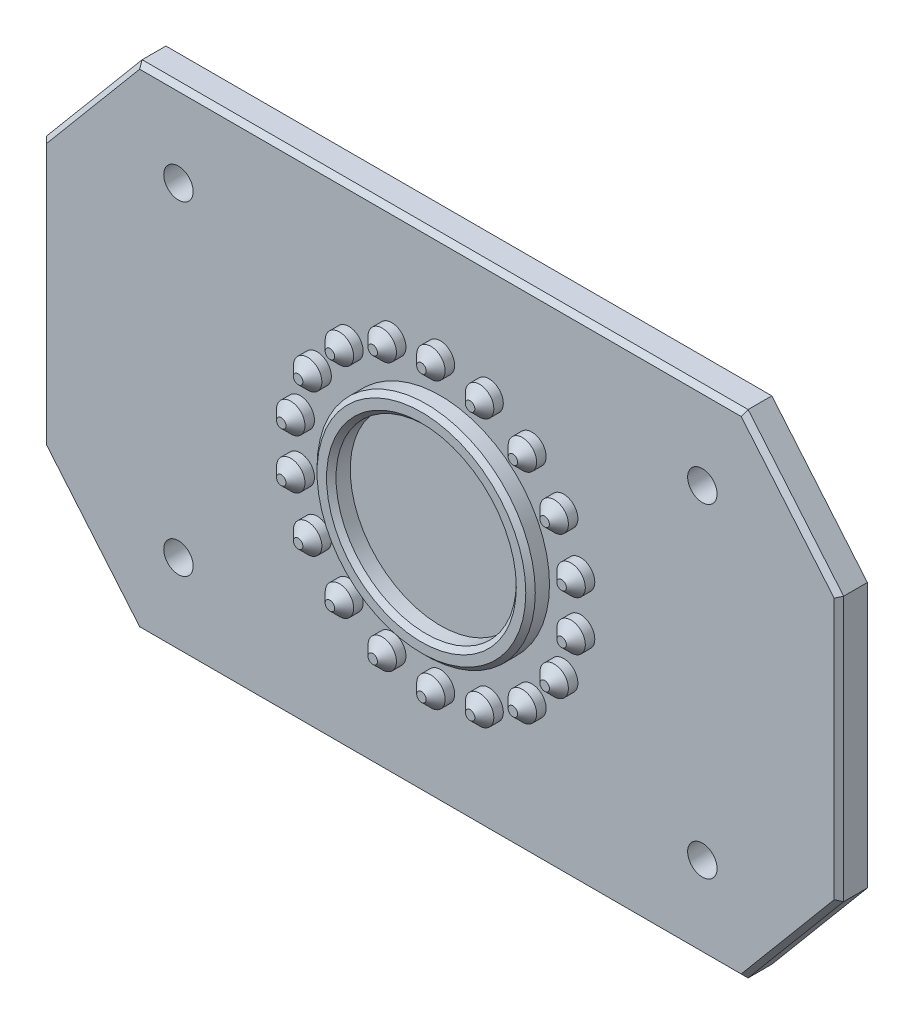
from build123d import *

# Parameters (mm, degrees)
SKETCH1_R           = 9.5
BOSS_EXTRUDE1_DEPTH = 3
CHAMFER1_SIZE       = 0.5
CUT_EXTRUDE1_REACH  = 124.813
SKETCH2_R           = 1.55
SKETCH3_R           = 1.5
BOSS_EXTRUDE2_DEPTH = 2
CHAMFER2_SIZE       = 1
SKETCH4_R           = 11.5
SKETCH4_R_2         = 9.5
BOSS_EXTRUDE3_DEPTH = 2
CHAMFER3_SIZE       = 0.5


with BuildPart() as part:
    # Sketch1 → Boss-Extrude1 (new body)
    with BuildSketch(Plane.XY):
        Polygon((-110, 14.650482688), (-99.930804426, 2.650482688), (-36.069195574, 2.650482688), (-26, 14.650482688), (-26, 42.534332436), (-36.069195574, 54.534332436), (-99.930804426, 54.534332436), (-110, 42.534332436), align=None)
        with Locations((-68, 28.592407562)):
            Circle(SKETCH1_R, mode=Mode.SUBTRACT)
        with Locations((-68, 28.592407562)):
            Circle(SKETCH1_R)
    extrude(amount=BOSS_EXTRUDE1_DEPTH)

    # Chamfer1
    chamfer1_edges = [part.edges().sort_by_distance(p)[0] for p in [
        (-31.034597787, 8.650482688, 3),
        (-26, 28.592407562, 3),
        (-31.034597787, 48.534332436, 3),
        (-68, 54.534332436, 3),
        (-104.965402213, 48.534332436, 3),
        (-110, 28.592407562, 3),
        (-104.965402213, 8.650482688, 3),
        (-68, 2.650482688, 3),
    ]]
    chamfer(chamfer1_edges, length=CHAMFER1_SIZE)

    # Sketch2 → Cut-Extrude1 (cut, up to next)
    with BuildSketch(Plane(origin=(0, 0, 0), x_dir=(-1, 0, 0), z_dir=(0, 0, -1)), mode=Mode.PRIVATE) as cut_extrude1_sk1:
        with Locations((40.392445123, 45.685066176)):
            Circle(SKETCH2_R)
    cut_extrude1_tool1 = extrude(cut_extrude1_sk1.sketch, amount=-CUT_EXTRUDE1_REACH, mode=Mode.PRIVATE) & part.part
    # Sketch2 → Cut-Extrude1 (cut, up to next)
    with BuildSketch(Plane(origin=(0, 0, 0), x_dir=(-1, 0, 0), z_dir=(0, 0, -1)), mode=Mode.PRIVATE) as cut_extrude1_sk2:
        with Locations((95.607554877, 45.685066176)):
            Circle(SKETCH2_R)
    cut_extrude1_tool2 = extrude(cut_extrude1_sk2.sketch, amount=-CUT_EXTRUDE1_REACH, mode=Mode.PRIVATE) & part.part
    # Sketch2 → Cut-Extrude1 (cut, up to next)
    with BuildSketch(Plane(origin=(0, 0, 0), x_dir=(-1, 0, 0), z_dir=(0, 0, -1)), mode=Mode.PRIVATE) as cut_extrude1_sk3:
        with Locations((95.607554877, 11.499748948)):
            Circle(SKETCH2_R)
    cut_extrude1_tool3 = extrude(cut_extrude1_sk3.sketch, amount=-CUT_EXTRUDE1_REACH, mode=Mode.PRIVATE) & part.part
    # Sketch2 → Cut-Extrude1 (cut, up to next)
    with BuildSketch(Plane(origin=(0, 0, 0), x_dir=(-1, 0, 0), z_dir=(0, 0, -1)), mode=Mode.PRIVATE) as cut_extrude1_sk4:
        with Locations((40.392445123, 11.499748948)):
            Circle(SKETCH2_R)
    cut_extrude1_tool4 = extrude(cut_extrude1_sk4.sketch, amount=-CUT_EXTRUDE1_REACH, mode=Mode.PRIVATE) & part.part
    add(cut_extrude1_tool1.solids().sort_by_distance((-40.392445, 45.685066, 0))[0], mode=Mode.SUBTRACT)
    add(cut_extrude1_tool2.solids().sort_by_distance((-95.607555, 45.685066, 0))[0], mode=Mode.SUBTRACT)
    add(cut_extrude1_tool3.solids().sort_by_distance((-95.607555, 11.499749, 0))[0], mode=Mode.SUBTRACT)
    add(cut_extrude1_tool4.solids().sort_by_distance((-40.392445, 11.499749, 0))[0], mode=Mode.SUBTRACT)

    # Sketch3 → Boss-Extrude2 (add)
    with BuildSketch(Plane.XY.offset(3)):
        with Locations((-68, 43.592407562)):
            Circle(SKETCH3_R)
        with Locations((-62.86969785, 42.687796874)):
            Circle(SKETCH3_R)
        with Locations((-58.358185855, 40.083074209)):
            Circle(SKETCH3_R)
        with Locations((-55.009618943, 36.092407562)):
            Circle(SKETCH3_R)
        with Locations((-53.227883705, 31.197130227)):
            Circle(SKETCH3_R)
        with Locations((-53.227883705, 25.987684897)):
            Circle(SKETCH3_R)
        with Locations((-55.009618943, 21.092407562)):
            Circle(SKETCH3_R)
        with Locations((-58.358185855, 17.101740915)):
            Circle(SKETCH3_R)
        with Locations((-62.86969785, 14.49701825)):
            Circle(SKETCH3_R)
        with Locations((-68, 13.592407562)):
            Circle(SKETCH3_R)
        with Locations((-73.13030215, 14.49701825)):
            Circle(SKETCH3_R)
        with Locations((-77.641814145, 17.101740915)):
            Circle(SKETCH3_R)
        with Locations((-80.990381057, 21.092407562)):
            Circle(SKETCH3_R)
        with Locations((-82.772116295, 25.987684897)):
            Circle(SKETCH3_R)
        with Locations((-82.772116295, 31.197130227)):
            Circle(SKETCH3_R)
        with Locations((-80.990381057, 36.092407562)):
            Circle(SKETCH3_R)
        with Locations((-77.641814145, 40.083074209)):
            Circle(SKETCH3_R)
        with Locations((-73.13030215, 42.687796874)):
            Circle(SKETCH3_R)
    extrude(amount=BOSS_EXTRUDE2_DEPTH)

    # Chamfer2
    chamfer2_edges = [part.edges().sort_by_distance(p)[0] for p in [
        (-79.141814145, 17.101740915, 5),
        (-82.490381057, 21.092407562, 5),
        (-84.272116295, 25.987684897, 5),
        (-84.272116295, 31.197130227, 5),
        (-82.490381057, 36.092407562, 5),
        (-79.141814145, 40.083074209, 5),
        (-74.63030215, 14.49701825, 5),
        (-74.63030215, 42.687796874, 5),
        (-69.5, 43.592407562, 5),
        (-64.36969785, 42.687796874, 5),
        (-59.858185855, 40.083074209, 5),
        (-56.509618943, 36.092407562, 5),
        (-54.727883705, 31.197130227, 5),
        (-54.727883705, 25.987684897, 5),
        (-56.509618943, 21.092407562, 5),
        (-59.858185855, 17.101740915, 5),
        (-64.36969785, 14.49701825, 5),
        (-69.5, 13.592407562, 5),
    ]]
    chamfer(chamfer2_edges, length=CHAMFER2_SIZE)

    # Sketch4 → Boss-Extrude3 (add)
    with BuildSketch(Plane.XY.offset(3)):
        with Locations((-68, 28.592407562)):
            Circle(SKETCH4_R)
        with Locations((-68, 28.592407562)):
            Circle(SKETCH4_R_2, mode=Mode.SUBTRACT)
    extrude(amount=BOSS_EXTRUDE3_DEPTH)

    # Chamfer3
    chamfer3_edges = [part.edges().sort_by_distance(p)[0] for p in [
        (-77.5, 28.592407562, 5),
        (-79.5, 28.592407562, 5),
    ]]
    chamfer(chamfer3_edges, length=CHAMFER3_SIZE)


solid = part.part
